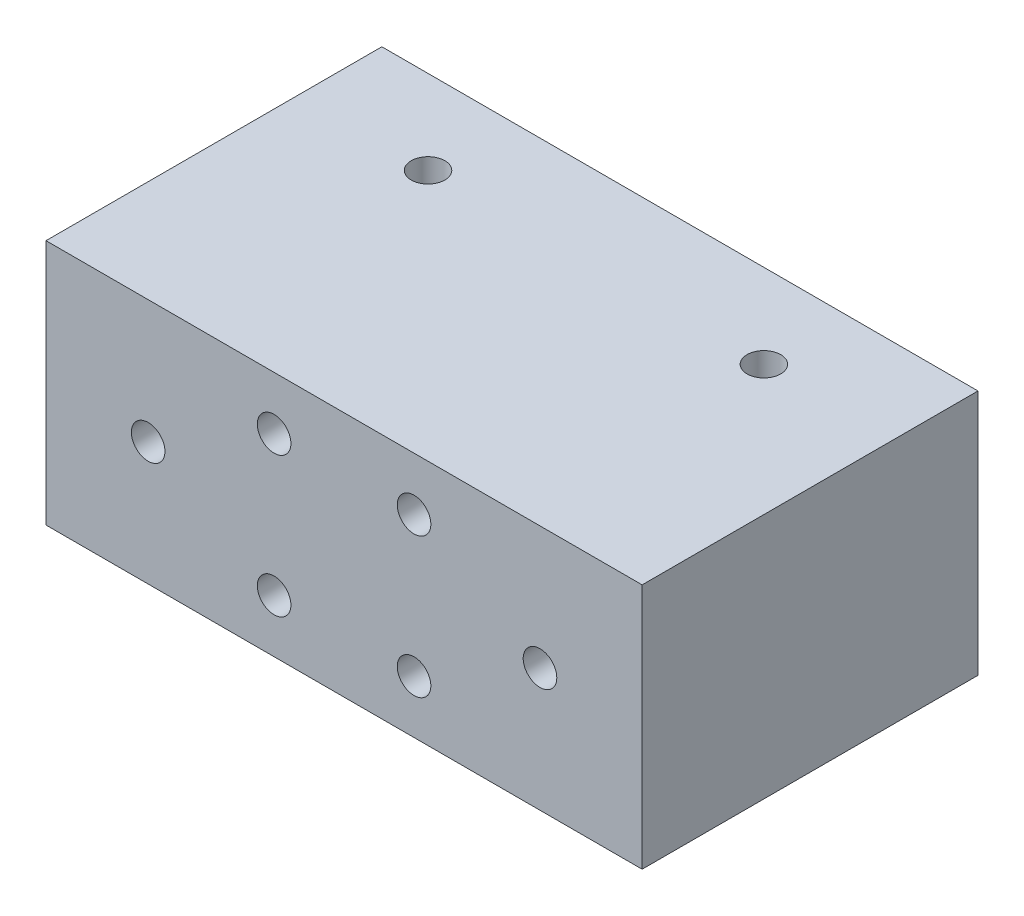
from build123d import *

# Parameters (mm, degrees)
CROQUIS1_W              = 42.6
CROQUIS1_H              = 17.6
SALIENTE_EXTRUIR1_DEPTH = 24
CROQUIS2_R              = 1.2
CORTAR_EXTRUIR1_DEPTH   = 24
CROQUIS4_R              = 1.2
CORTAR_EXTRUIR2_DEPTH   = 10


with BuildPart() as part:
    # Croquis1 → Saliente-Extruir1 (new body)
    with BuildSketch(Plane.XY):
        Rectangle(CROQUIS1_W, CROQUIS1_H)
    extrude(amount=SALIENTE_EXTRUIR1_DEPTH)

    # Croquis2 → Cortar-Extruir1 (cut)
    with BuildSketch(Plane(origin=(0, 8.8, 0), x_dir=(1, 0, 0), z_dir=(0, 1, 0))):
        with Locations((-12, -6)):
            Circle(CROQUIS2_R)
        with Locations((12, -6)):
            Circle(CROQUIS2_R)
    extrude(amount=-CORTAR_EXTRUIR1_DEPTH, mode=Mode.SUBTRACT)

    # Croquis4 → Cortar-Extruir2 (cut)
    with BuildSketch(Plane.XY.offset(24)):
        with Locations((-14, 0)):
            Circle(CROQUIS4_R)
        with Locations((-5, 5)):
            Circle(CROQUIS4_R)
        with Locations((5, 5)):
            Circle(CROQUIS4_R)
        with Locations((14, 0)):
            Circle(CROQUIS4_R)
        with Locations((5, -5)):
            Circle(CROQUIS4_R)
        with Locations((-5, -5)):
            Circle(CROQUIS4_R)
    extrude(amount=-CORTAR_EXTRUIR2_DEPTH, mode=Mode.SUBTRACT)


solid = part.part
